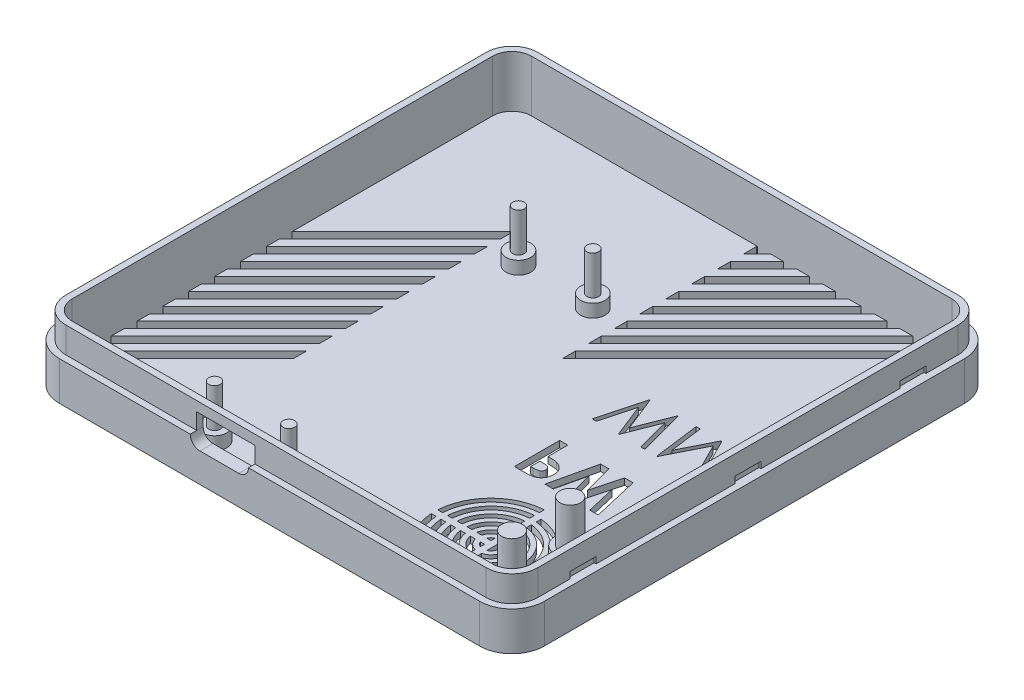
from build123d import *
from build123d.topology import SkipClean

# Parameters (mm, degrees)
SZKIC1_W                        = 75
SZKIC1_H                        = 75
DODANIE_WYCI_GNI_CIE1_DEPTH     = 10
ZAOKR_GLENIE1_R                 = 5
WYTNIJ_WYCI_GNI_CIE1_DEPTH      = 8
WYTNIJ_WYCI_GNI_CIE2_DEPTH      = 4
SZKIC7_R                        = 1.9
SZKIC7_R_2                      = 0.9
SZKIC7_R_3                      = 1.900523095
SZKIC7_R_4                      = 0.900523095
DODANIE_WYCI_GNI_CIE2_DEPTH     = 2
SZKIC9_R                        = 0.900523095
SZKIC9_R_2                      = 0.9
DODANIE_WYCI_GNI_CIE3_DEPTH     = 8
SZKIC10_R                       = 1.6
DODANIE_WYCI_GNI_CIE4_DEPTH     = 8
SZKIC11_R                       = 2.35
SZKIC11_R_2                     = 1.6
DODANIE_WYCI_GNI_CIE5_DEPTH     = 1.5
WYTNIJ_WYCI_GNI_CIE13_DEPTH     = 10
WYTNIJ_WYCI_GNI_CIE6_DEPTH      = 1
WYTNIJ_WYCI_GNI_CIE9_DEPTH      = 107.447169995
WYTNIJ_WYCI_GNI_CIE9_DEPTH_BACK = 107.447169995
SZKIC20_W                       = 4
SZKIC20_H                       = 1
WYTNIJ_WYCI_GNI_CIE11_DEPTH     = 0.3
SZKIC21_W                       = 4
SZKIC21_H                       = 1
WYTNIJ_WYCI_GNI_CIE12_DEPTH     = 0.3
WYTNIJ_WYCI_GNI_CIE14_DEPTH     = 10
WYTNIJ_WYCI_GNI_CIE15_DEPTH     = 10


with BuildPart() as part:
    # Szkic1 → Dodanie-wyciągnięcie1 (new body)
    with BuildSketch(Plane(origin=(0, 0, 0), x_dir=(1, 0, 0), z_dir=(0, 1, 0))):
        with Locations((37.5, 37.5)):
            Rectangle(SZKIC1_W, SZKIC1_H)
    extrude(amount=DODANIE_WYCI_GNI_CIE1_DEPTH)

    # Zaokrąglenie1
    zaokr_glenie1_edges = [part.edges().sort_by_distance(p)[0] for p in [
        (0, 5, 0),
        (0, 5, -75),
        (75, 5, -75),
        (75, 5, 0),
    ]]
    fillet(zaokr_glenie1_edges, radius=ZAOKR_GLENIE1_R)

    # Szkic4 → Wytnij-wyciągnięcie1 (cut)
    with BuildSketch(Plane(origin=(0, 10, 0), x_dir=(1, 0, 0), z_dir=(0, 1, 0))):
        with BuildLine():
            Line((2, 70), (2, 5))
            ThreePointArc((2, 5), (2.878679656, 2.878679656), (5, 2))
            Line((5, 2), (70, 2))
            ThreePointArc((70, 2), (72.121320344, 2.878679656), (73, 5))
            Line((73, 5), (73, 70))
            ThreePointArc((73, 70), (72.121320344, 72.121320344), (70, 73))
            Line((70, 73), (5, 73))
            ThreePointArc((5, 73), (2.878679656, 72.121320344), (2, 70))
        make_face()
    extrude(amount=-WYTNIJ_WYCI_GNI_CIE1_DEPTH, mode=Mode.SUBTRACT)

    # Szkic6 → Wytnij-wyciągnięcie2 (cut)
    with BuildSketch(Plane(origin=(0, 10, 0), x_dir=(1, 0, 0), z_dir=(0, 1, 0))):
        with BuildLine():
            Line((70, 75), (5, 75))
            ThreePointArc((5, 75), (1.464466094, 73.535533906), (0, 70))
            Line((0, 70), (0, 5))
            ThreePointArc((0, 5), (1.464466094, 1.464466094), (5, 0))
            Line((5, 0), (70, 0))
            ThreePointArc((70, 0), (73.535533906, 1.464466094), (75, 5))
            Line((75, 5), (75, 70))
            ThreePointArc((75, 70), (73.535533906, 73.535533906), (70, 75))
        make_face()
        with BuildLine():
            Line((1, 70), (1, 5))
            ThreePointArc((1, 5), (2.171572875, 2.171572875), (5, 1))
            Line((5, 1), (70, 1))
            ThreePointArc((70, 1), (72.828427125, 2.171572875), (74, 5))
            Line((74, 5), (74, 70))
            ThreePointArc((74, 70), (72.828427125, 72.828427125), (70, 74))
            Line((70, 74), (5, 74))
            ThreePointArc((5, 74), (2.171572875, 72.828427125), (1, 70))
        make_face(mode=Mode.SUBTRACT)
    extrude(amount=-WYTNIJ_WYCI_GNI_CIE2_DEPTH, mode=Mode.SUBTRACT)

    # Szkic7 → Dodanie-wyciągnięcie2 (add)
    with BuildSketch(Plane(origin=(0, 2, 0), x_dir=(1, 0, 0), z_dir=(0, 1, 0))):
        with Locations(Location((24, 52, 0), (0, 0, 270))):
            Circle(SZKIC7_R)
        with Locations(Location((24, 52, 0), (0, 0, 270))):
            Circle(SZKIC7_R_2, mode=Mode.SUBTRACT)
        with Locations(Location((35.5, 52, 0), (0, 0, 270))):
            Circle(SZKIC7_R_3)
        with Locations(Location((35.5, 52, 0), (0, 0, 270))):
            Circle(SZKIC7_R_4, mode=Mode.SUBTRACT)
        with Locations(Location((35.5, 5, 0), (0, 0, 270))):
            Circle(SZKIC7_R)
        with Locations(Location((35.5, 5, 0), (0, 0, 270))):
            Circle(SZKIC7_R_2, mode=Mode.SUBTRACT)
        with Locations(Location((24, 5, 0), (0, 0, 270))):
            Circle(SZKIC7_R)
        with Locations(Location((24, 5, 0), (0, 0, 270))):
            Circle(SZKIC7_R_2, mode=Mode.SUBTRACT)
    extrude(amount=DODANIE_WYCI_GNI_CIE2_DEPTH)

    # Szkic9 → Dodanie-wyciągnięcie3 (add)
    with BuildSketch(Plane(origin=(0, 2, 0), x_dir=(1, 0, 0), z_dir=(0, 1, 0))):
        with Locations(Location((35.5, 52, 0), (0, 0, 270))):
            Circle(SZKIC9_R)
        with Locations(Location((35.5, 5, 0), (0, 0, 270))):
            Circle(SZKIC9_R_2)
        with Locations(Location((24, 5, 0), (0, 0, 270))):
            Circle(SZKIC9_R_2)
        with Locations(Location((24, 52, 0), (0, 0, 270))):
            Circle(SZKIC9_R_2)
    extrude(amount=DODANIE_WYCI_GNI_CIE3_DEPTH)

    # Szkic10 → Dodanie-wyciągnięcie4 (add)
    with BuildSketch(Plane(origin=(0, 2, 0), x_dir=(1, 0, 0), z_dir=(0, 1, 0))):
        with Locations(Location((67, 17, 0), (0, 0, 270))):
            Circle(SZKIC10_R)
        with Locations(Location((67, 8, 0), (0, 0, 270))):
            Circle(SZKIC10_R)
    extrude(amount=DODANIE_WYCI_GNI_CIE4_DEPTH)

    # Szkic11 → Dodanie-wyciągnięcie5 (add)
    with BuildSketch(Plane(origin=(0, 2, 0), x_dir=(1, 0, 0), z_dir=(0, 1, 0))):
        with Locations(Location((67, 17, 0), (0, 0, 270))):
            Circle(SZKIC11_R)
        with Locations(Location((67, 17, 0), (0, 0, 270))):
            Circle(SZKIC11_R_2, mode=Mode.SUBTRACT)
        with Locations(Location((67, 8, 0), (0, 0, 270))):
            Circle(SZKIC11_R)
        with Locations(Location((67, 8, 0), (0, 0, 270))):
            Circle(SZKIC11_R_2, mode=Mode.SUBTRACT)
    extrude(amount=DODANIE_WYCI_GNI_CIE5_DEPTH)

    # Szkic15 → Wytnij-wyciągnięcie13 (cut)
    with SkipClean():  # the faces are left unmerged after this step: merging them gives an invalid solid
        with BuildSketch(Plane(origin=(0, 2, 0), x_dir=(1, 0, 0), z_dir=(0, 1, 0))):
            with BuildLine():
                Line((58.75, 20.484359711), (58.75, 21.235702605))
                ThreePointArc((58.75, 21.235702605), (53.062815665, 18.687184335), (50.514297395, 13))
                Line((50.514297395, 13), (51.265640289, 13))
                ThreePointArc((51.265640289, 13), (53.593145751, 18.156854249), (58.75, 20.484359711))
            make_face()
            with BuildLine():
                Line((58.75, 18.980740698), (58.75, 19.732738071))
                ThreePointArc((58.75, 19.732738071), (54.123475836, 17.626524164), (52.017261929, 13))
                Line((52.017261929, 13), (52.769259302, 13))
                ThreePointArc((52.769259302, 13), (54.653805922, 17.096194078), (58.75, 18.980740698))
            make_face()
            with BuildLine():
                ThreePointArc((64.671070874, 17.313989051), (62.448023886, 19.006546182), (59.75, 19.732738071))
                Line((59.75, 19.732738071), (59.75, 18.980740698))
                ThreePointArc((59.75, 18.980740698), (63.63562173, 17.297532912), (65.659949819, 13.578213019))
                Line((65.659949819, 13.578213019), (66.379128146, 13.818344367))
                ThreePointArc((66.379128146, 13.818344367), (66.266621006, 14.32469988), (66.118197609, 14.821715229))
                ThreePointArc((66.118197609, 14.821715229), (64.967745975, 15.819981534), (64.671070874, 17.313989051))
            make_face()
            with BuildLine():
                ThreePointArc((67.8134326, 14.297254047), (67.761672304, 14.528283654), (67.703680347, 14.757828292))
                ThreePointArc((67.703680347, 14.757828292), (67.333967662, 14.673851767), (66.955562473, 14.650420185))
                ThreePointArc((66.955562473, 14.650420185), (67.031834613, 14.355545757), (67.096826939, 14.057981704))
                Line((67.096826939, 14.057981704), (67.8134326, 14.297254047))
            make_face()
            with BuildLine():
                Line((58.75, 17.474937186), (58.75, 18.228219619))
                ThreePointArc((58.75, 18.228219619), (55.184136008, 16.565863992), (53.521780381, 13))
                Line((53.521780381, 13), (54.275062814, 13))
                ThreePointArc((54.275062814, 13), (55.714466094, 16.035533906), (58.75, 17.474937186))
            make_face()
            with BuildLine():
                Line((51.265640289, 12), (50.514297395, 12))
                ThreePointArc((50.514297395, 12), (53.062815665, 6.312815665), (58.75, 3.764297395))
                Line((58.75, 3.764297395), (58.75, 4.515640289))
                ThreePointArc((58.75, 4.515640289), (53.593145751, 6.843145751), (51.265640289, 12))
            make_face()
            with BuildLine():
                Line((64.993916764, 12.235575707), (67.985446103, 11.995538529))
                ThreePointArc((67.985446103, 11.995538529), (67.985574639, 11.997769248), (67.985702605, 12))
                ThreePointArc((67.985702605, 12), (68, 12.5), (67.985702605, 13))
                ThreePointArc((67.985702605, 13), (67.985574639, 13.002230752), (67.985446103, 13.004461471))
                Line((67.985446103, 13.004461471), (64.993916764, 12.764424293))
                ThreePointArc((64.993916764, 12.764424293), (63.398480322, 16.481533752), (59.75, 18.228219619))
                Line((59.75, 18.228219619), (59.75, 17.474937186))
                ThreePointArc((59.75, 17.474937186), (64.25, 12.5), (59.75, 7.525062814))
                Line((59.75, 7.525062814), (59.75, 6.771780381))
                ThreePointArc((59.75, 6.771780381), (63.398480322, 8.518466248), (64.993916764, 12.235575707))
            make_face()
            with BuildLine():
                Line((58.75, 15.964101615), (58.75, 16.720485754))
                ThreePointArc((58.75, 16.720485754), (56.24479618, 15.50520382), (55.029514246, 13))
                Line((55.029514246, 13), (55.785898385, 13))
                ThreePointArc((55.785898385, 13), (56.775126266, 14.974873734), (58.75, 15.964101615))
            make_face()
            with BuildLine():
                Line((52.769259302, 12), (52.017261929, 12))
                ThreePointArc((52.017261929, 12), (54.123475836, 7.373475836), (58.75, 5.267261929))
                Line((58.75, 5.267261929), (58.75, 6.019259302))
                ThreePointArc((58.75, 6.019259302), (54.653805922, 7.903805922), (52.769259302, 12))
            make_face()
            with BuildLine():
                Line((59.75, 16.720485754), (59.75, 15.964101615))
                ThreePointArc((59.75, 15.964101615), (62.75, 12.5), (59.75, 9.035898385))
                Line((59.75, 9.035898385), (59.75, 8.279514246))
                ThreePointArc((59.75, 8.279514246), (63.5, 12.5), (59.75, 16.720485754))
            make_face()
            with BuildLine():
                Line((58.75, 14.436491673), (58.75, 15.204163457))
                ThreePointArc((58.75, 15.204163457), (57.305456352, 14.444543648), (56.545836543, 13))
                Line((56.545836543, 13), (57.313508327, 13))
                ThreePointArc((57.313508327, 13), (57.835786438, 13.914213562), (58.75, 14.436491673))
            make_face()
            with BuildLine():
                Line((54.275062814, 12), (53.521780381, 12))
                ThreePointArc((53.521780381, 12), (55.184136008, 8.434136008), (58.75, 6.771780381))
                Line((58.75, 6.771780381), (58.75, 7.525062814))
                ThreePointArc((58.75, 7.525062814), (55.714466094, 8.964466094), (54.275062814, 12))
            make_face()
            with BuildLine():
                Line((59.75, 15.204163457), (59.75, 14.436491673))
                ThreePointArc((59.75, 14.436491673), (61.25, 12.5), (59.75, 10.563508327))
                Line((59.75, 10.563508327), (59.75, 9.795836543))
                ThreePointArc((59.75, 9.795836543), (62, 12.5), (59.75, 15.204163457))
            make_face()
            with BuildLine():
                Line((58.75, 13), (58.75, 13.645643924))
                ThreePointArc((58.75, 13.645643924), (58.366116524, 13.383883476), (58.104356076, 13))
                Line((58.104356076, 13), (58.75, 13))
            make_face()
            with BuildLine():
                Line((55.785898385, 12), (55.029514246, 12))
                ThreePointArc((55.029514246, 12), (56.24479618, 9.49479618), (58.75, 8.279514246))
                Line((58.75, 8.279514246), (58.75, 9.035898385))
                ThreePointArc((58.75, 9.035898385), (56.775126266, 10.025126266), (55.785898385, 12))
            make_face()
            with BuildLine():
                Line((59.75, 6.019259302), (59.75, 5.267261929))
                ThreePointArc((59.75, 5.267261929), (62.448023886, 5.993453818), (64.671070874, 7.686010949))
                ThreePointArc((64.671070874, 7.686010949), (64.967745975, 9.180018466), (66.118197609, 10.178284771))
                ThreePointArc((66.118197609, 10.178284771), (66.271306398, 10.693413035), (66.385837318, 11.218467413))
                Line((66.385837318, 11.218467413), (65.66905759, 11.477405427))
                ThreePointArc((65.66905759, 11.477405427), (63.656379383, 7.721525271), (59.75, 6.019259302))
            make_face()
            with BuildLine():
                ThreePointArc((66.955562473, 10.349579815), (67.333967662, 10.326148233), (67.703680347, 10.242171708))
                ThreePointArc((67.703680347, 10.242171708), (67.761672304, 10.471716346), (67.8134326, 10.702745953))
                Line((67.8134326, 10.702745953), (67.100437892, 10.960316622))
                ThreePointArc((67.100437892, 10.960316622), (67.033992337, 10.653526794), (66.955562473, 10.349579815))
            make_face()
            with BuildLine():
                Line((59.75, 13.645643924), (59.75, 11.354356076))
                ThreePointArc((59.75, 11.354356076), (60.5, 12.5), (59.75, 13.645643924))
            make_face()
            with BuildLine():
                Line((57.313508327, 12), (56.545836543, 12))
                ThreePointArc((56.545836543, 12), (57.305456352, 10.555456352), (58.75, 9.795836543))
                Line((58.75, 9.795836543), (58.75, 10.563508327))
                ThreePointArc((58.75, 10.563508327), (57.835786438, 11.085786438), (57.313508327, 12))
            make_face()
            with BuildLine():
                Line((58.75, 12), (58.104356076, 12))
                ThreePointArc((58.104356076, 12), (58.366116524, 11.616116524), (58.75, 11.354356076))
                Line((58.75, 11.354356076), (58.75, 12))
            make_face()
        extrude(amount=-WYTNIJ_WYCI_GNI_CIE13_DEPTH, mode=Mode.SUBTRACT)

    # Szkic16 → Wytnij-wyciągnięcie6 (cut)
    with BuildSketch(Plane.XZ):
        with BuildLine():
            Line((70, -1), (5, -1))
            ThreePointArc((5, -1), (2.171572875, -2.171572875), (1, -5))
            Line((1, -5), (1, -70))
            ThreePointArc((1, -70), (2.171572875, -72.828427125), (5, -74))
            Line((5, -74), (70, -74))
            ThreePointArc((70, -74), (72.828427125, -72.828427125), (74, -70))
            Line((74, -70), (74, -5))
            ThreePointArc((74, -5), (72.828427125, -2.171572875), (70, -1))
        make_face()
    extrude(amount=-WYTNIJ_WYCI_GNI_CIE6_DEPTH, mode=Mode.SUBTRACT)

    # Szkic18 → Wytnij-wyciągnięcie9 (cut, two sides)
    with BuildSketch(Plane.XZ.offset(-1)) as wytnij_wyci_gni_cie9_sk:
        with BuildLine():
            Line((50.642144747, -24.727187051), (52.044388337, -24.727187051))
            add(Edge.make_bspline(
                [(52.044388337, -24.727187051), (52.136009114, -24.727597165), (52.312764798, -24.728388361), (52.567661036, -24.737982665), (52.802815297, -24.755176244), (53.018173552, -24.776424788), (53.213647254, -24.806214419), (53.389481193, -24.8403659), (53.545711859, -24.881972342), (53.684100985, -24.931358613), (53.808300756, -24.989583097), (53.925833797, -25.051596328), (54.034043849, -25.125606933), (54.1383926, -25.203638362), (54.232914251, -25.293144927), (54.323505631, -25.388169838), (54.406329946, -25.492481704), (54.481770973, -25.604817857), (54.550207609, -25.723102807), (54.609998433, -25.847548011), (54.658497401, -25.97835039), (54.699182005, -26.114663804), (54.731860275, -26.256482309), (54.753611972, -26.404678104), (54.768386818, -26.558216428), (54.769690494, -26.662714708), (54.770349875, -26.715568461)],
                knots=[0, 0, 0, 0, 1.698747864, 3.27724071, 4.728299578, 6.070144658, 7.288476769, 8.393259625, 9.389771311, 10.283485332, 11.113357557, 11.931608583, 12.74405601, 13.541433047, 14.344816069, 15.154114104, 15.974336324, 16.810834471, 17.661136416, 18.50621059, 19.367396281, 20.244825668, 21.142564693, 22.063065223, 23.020325768, 24, 24, 24, 24], degree=3))
            add(Edge.make_bspline(
                [(54.770349875, -26.715568461), (54.769395834, -26.774039309), (54.767521024, -26.888941712), (54.749141852, -27.057374537), (54.717744418, -27.217959987), (54.676709615, -27.372052306), (54.619489499, -27.517116334), (54.554118204, -27.656613345), (54.473690777, -27.786632269), (54.381789583, -27.908799487), (54.281422995, -28.024108276), (54.170208314, -28.129229314), (54.05026534, -28.224879205), (53.92228838, -28.312060369), (53.78579697, -28.390596943), (53.640889594, -28.461224336), (53.486576744, -28.521683667), (53.379117918, -28.553303408), (53.324636734, -28.569334486)],
                knots=[0, 0, 0, 0, 1.102006807, 2.165578795, 3.188629044, 4.184801286, 5.166646146, 6.124351954, 7.085497154, 8.042432466, 9.003981491, 9.963833307, 10.922997304, 11.89326795, 12.880200226, 13.889073926, 14.929769137, 16, 16, 16, 16], degree=3))
            add(Edge.make_bspline(
                [(53.324636734, -28.569334486), (53.288752293, -28.578262594), (53.211015036, -28.597603749), (53.082381228, -28.617239876), (52.934144271, -28.635294087), (52.765824816, -28.650809496), (52.577325825, -28.661356359), (52.368829813, -28.66959299), (52.140242293, -28.675581871), (51.981291571, -28.675794383), (51.898555004, -28.675904999)],
                knots=[0, 0, 0, 0, 0.618981996, 1.340914327, 2.176866532, 3.120127938, 4.170906482, 5.338178032, 6.614476169, 8, 8, 8, 8], degree=3))
            Line((51.898555004, -28.675904999), (51.898555004, -31.727187051))
            Line((51.898555004, -31.727187051), (50.642144747, -31.727187051))
            Line((50.642144747, -31.727187051), (50.642144747, -24.727187051))
        make_face()
        with BuildLine():
            Line((51.898555004, -27.419494743), (52.343066222, -27.419494743))
            add(Edge.make_bspline(
                [(52.343066222, -27.419494743), (52.423952056, -27.418981864), (52.572783192, -27.418038159), (52.776033966, -27.404391637), (52.939370199, -27.383550642), (53.068408855, -27.353659835), (53.170297097, -27.308296578), (53.258169326, -27.255819832), (53.333539581, -27.189464427), (53.398799128, -27.113642023), (53.450972169, -27.02651828), (53.487151455, -26.92951184), (53.510652809, -26.824660912), (53.512823377, -26.751691606), (53.513939619, -26.714166217)],
                knots=[0, 0, 0, 0, 1.8619151, 3.425951444, 4.686033666, 5.651700536, 6.461346321, 7.243864085, 7.999046032, 8.762387399, 9.539336099, 10.322741239, 11.137448474, 12, 12, 12, 12], degree=3))
            add(Edge.make_bspline(
                [(53.513939619, -26.714166217), (53.512834859, -26.681380774), (53.510691359, -26.617769132), (53.494944623, -26.525961754), (53.469848855, -26.440378338), (53.433486052, -26.361912691), (53.386477559, -26.290698137), (53.329164692, -26.226762732), (53.26228289, -26.168737243), (53.210646227, -26.138023465), (53.184412375, -26.122419422)],
                knots=[0, 0, 0, 0, 1.102301479, 2.1387299, 3.123554645, 4.094223062, 5.036071848, 5.982632524, 6.975082478, 8, 8, 8, 8], degree=3))
            add(Edge.make_bspline(
                [(53.184412375, -26.122419422), (53.162190788, -26.111181329), (53.115143135, -26.087387981), (53.03501642, -26.059726475), (52.942551415, -26.036390948), (52.837123876, -26.017022685), (52.719154384, -26.001990902), (52.588663987, -25.990495348), (52.445460656, -25.985872538), (52.345871308, -25.984376636), (52.293987696, -25.983597307)],
                knots=[0, 0, 0, 0, 0.656809284, 1.390599849, 2.23162475, 3.173112763, 4.218524733, 5.370385145, 6.63003504, 8, 8, 8, 8], degree=3))
            Line((52.293987696, -25.983597307), (51.898555004, -25.983597307))
            Line((51.898555004, -25.983597307), (51.898555004, -27.419494743))
        make_face(mode=Mode.SUBTRACT)
        Polygon((55.353683209, -24.727187051), (56.650758529, -24.727187051), (57.687016542, -29.196137371), (58.874716863, -24.727187051), (60.096071029, -24.727187051), (61.276760132, -29.196137371), (62.310213657, -24.727187051), (63.610093465, -24.727187051), (61.990502119, -31.727187051), (60.678002119, -31.727187051), (59.481888337, -27.202146986), (58.278763337, -31.727187051), (56.976079042, -31.727187051), align=None)
        Polygon((50.283170388, -37.124622948), (50.93240917, -37.124622948), (52.302401157, -42.25823673), (54.339861093, -37.124622948), (54.431006927, -37.124622948), (56.430606286, -42.22318064), (57.807609491, -37.124622948), (58.449837055, -37.124622948), (56.562417183, -44.124622948), (56.472673593, -44.124622948), (54.366503722, -38.770856922), (52.235093465, -44.124622948), (52.145349875, -44.124622948), align=None)
        Polygon((59.347272952, -44.124622948), (60.271351478, -37.124622948), (60.361095068, -37.124622948), (63.251119106, -42.868212692), (66.134131927, -37.124622948), (66.22527776, -37.124622948), (67.15496526, -44.124622948), (66.523955645, -44.124622948), (65.853683209, -39.087763974), (63.32684026, -44.124622948), (63.185213657, -44.124622948), (60.648555004, -39.076546025), (59.979684811, -44.124622948), align=None)
        Polygon((67.783170388, -37.842571666), (67.783170388, -37.124622948), (71.462657568, -37.124622948), (71.462657568, -37.842571666), (69.937016542, -37.842571666), (69.937016542, -44.124622948), (69.308811414, -44.124622948), (69.308811414, -37.842571666), align=None)
    extrude(amount=WYTNIJ_WYCI_GNI_CIE9_DEPTH, mode=Mode.SUBTRACT)
    extrude(wytnij_wyci_gni_cie9_sk.sketch, amount=-WYTNIJ_WYCI_GNI_CIE9_DEPTH_BACK, mode=Mode.SUBTRACT)


with BuildPart() as wytnij_wyci_gni_cie9_piece_1:
    # of the separate pieces the step leaves, piece 1, a body of its own (wytnij_wyci_gni_cie9_pieces)
    add(part.part.solids().sort_by_distance((0, 0, -5))[0])

    # Szkic20 → Wytnij-wyciągnięcie11 (cut)
    with BuildSketch(Plane.ZY.offset(-1)):
        with Locations((-63, 6.5)):
            Rectangle(SZKIC20_W, SZKIC20_H)
        with Locations((-12, 6.5)):
            Rectangle(SZKIC20_W, SZKIC20_H)
        with Locations((-37.5, 6.5)):
            Rectangle(SZKIC20_W, SZKIC20_H)
    extrude(amount=-WYTNIJ_WYCI_GNI_CIE11_DEPTH, mode=Mode.SUBTRACT)

    # Szkic21 → Wytnij-wyciągnięcie12 (cut)
    with BuildSketch(Plane(origin=(74, 0, 0), x_dir=(0, 0, -1), z_dir=(1, 0, 0))):
        with Locations((12, 6.5)):
            Rectangle(SZKIC21_W, SZKIC21_H)
        with Locations((63, 6.5)):
            Rectangle(SZKIC21_W, SZKIC21_H)
        with Locations((37.5, 6.5)):
            Rectangle(SZKIC21_W, SZKIC21_H)
    extrude(amount=-WYTNIJ_WYCI_GNI_CIE12_DEPTH, mode=Mode.SUBTRACT)

    # Szkic14 → Wytnij-wyciągnięcie14 (cut)
    with BuildSketch(Plane(origin=(0, 2, 0), x_dir=(1, 0, 0), z_dir=(0, 1, 0))):
        Polygon((19.102817133, 22.102817133), (19.102817133, 24.102817133), (2, 7), (2, 5), align=None)
        Polygon((19.102817133, 26.102817133), (19.102817133, 28.102817133), (2, 11), (2, 9), align=None)
        Polygon((19.102817133, 30.102817133), (19.102817133, 32.102817133), (2, 15), (2, 13), align=None)
        Polygon((19.102817133, 34.102817133), (19.102817133, 36.102817133), (2, 19), (2, 17), align=None)
        Polygon((19.102817133, 38.102817133), (19.102817133, 40.102817133), (2, 23), (2, 21), align=None)
        Polygon((2, 25), (19.102817133, 42.102817133), (19.102817133, 44.102817133), (2, 27), align=None)
        Polygon((2, 29), (19.102817133, 46.102817133), (19.102817133, 48.102817133), (2, 31), align=None)
        Polygon((2, 33), (19.102817133, 50.102817133), (19.102817133, 52.102817133), (2, 35), align=None)
        Polygon((2, 37), (19.102817133, 54.102817133), (19.102817133, 56.102817133), (2, 39), align=None)
        Polygon((39.899048849, 70.899048849), (42, 73), (40, 73), (39.899048849, 72.899048849), align=None)
        Polygon((39.899048849, 66.899048849), (46, 73), (44, 73), (39.899048849, 68.899048849), align=None)
        Polygon((39.899048849, 62.899048849), (50, 73), (48, 73), (39.899048849, 64.899048849), align=None)
        Polygon((54, 73), (52, 73), (39.899048849, 60.899048849), (39.899048849, 58.899048849), align=None)
        Polygon((58, 73), (56, 73), (39.899048849, 56.899048849), (39.899048849, 54.899048849), align=None)
        Polygon((62, 73), (60, 73), (39.899048849, 52.899048849), (39.899048849, 50.899048849), align=None)
        Polygon((66, 73), (64, 73), (39.899048849, 48.899048849), (39.899048849, 46.899048849), align=None)
        Polygon((70, 73), (68, 73), (39.899048849, 44.899048849), (39.899048849, 42.899048849), align=None)
    extrude(amount=-WYTNIJ_WYCI_GNI_CIE14_DEPTH, mode=Mode.SUBTRACT)

    # Szkic19 → Wytnij-wyciągnięcie15 (cut)
    with BuildSketch(Plane(origin=(0, 0, -2), x_dir=(-1, 0, 0), z_dir=(0, 0, -1))):
        with BuildLine():
            Line((-32.75, 4.5), (-26.75, 4.5))
            ThreePointArc((-26.75, 4.5), (-25.689339828, 4.939339828), (-25.25, 6))
            Line((-25.25, 6), (-25.25, 8.5))
            Line((-25.25, 8.5), (-34.25, 8.5))
            Line((-34.25, 8.5), (-34.25, 6))
            ThreePointArc((-34.25, 6), (-33.810660172, 4.939339828), (-32.75, 4.5))
        make_face()
    extrude(amount=-WYTNIJ_WYCI_GNI_CIE15_DEPTH, mode=Mode.SUBTRACT)


with BuildPart() as wytnij_wyci_gni_cie9_piece_2:
    # of the separate pieces the step leaves, piece 2, a body of its own (wytnij_wyci_gni_cie9_pieces)
    add(part.part.solids().sort_by_distance((53.513939619, 1, -26.714166217))[0])


solid = Compound([wytnij_wyci_gni_cie9_piece_1.part, wytnij_wyci_gni_cie9_piece_2.part])
